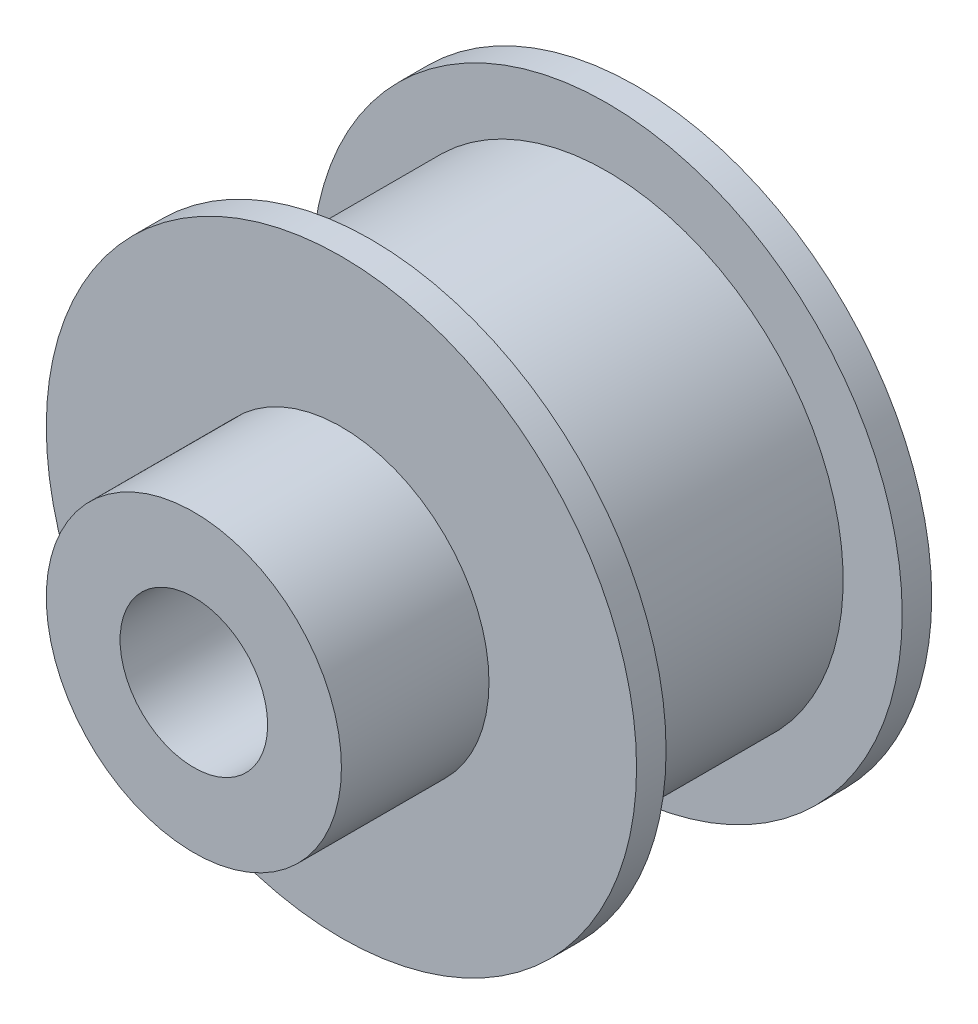
from build123d import *

# Parameters (mm, degrees)
ESQUISSE1_R             = 10
BOSS_EXTRU_1_DEPTH      = 10
ESQUISSE2_R             = 5
BOSS_EXTRU_2_DEPTH      = 5
ESQUISSE3_R             = 2.5
ENL_V_MAT_EXTRU_1_DEPTH = 16
ESQUISSE4_W             = 8
ESQUISSE4_H             = 2


with BuildPart() as part:
    # Esquisse1 → Boss.-Extru.1 (new body)
    with BuildSketch(Plane.XY):
        Circle(ESQUISSE1_R)
    extrude(amount=BOSS_EXTRU_1_DEPTH)

    # Esquisse2 → Boss.-Extru.2 (add)
    with BuildSketch(Plane.XY.offset(10)):
        Circle(ESQUISSE2_R)
    extrude(amount=BOSS_EXTRU_2_DEPTH)

    # Esquisse3 → Enlèv. mat.-Extru.1 (cut, through all)
    with BuildSketch(Plane.XY.offset(15)):
        Circle(ESQUISSE3_R)
    extrude(amount=-ENL_V_MAT_EXTRU_1_DEPTH, mode=Mode.SUBTRACT)

    # Esquisse4 → Enlèvement de matière-Révolution1 (revolve, cut)
    with BuildSketch(Plane(origin=(0, 0, 0), x_dir=(0, 0, -1), z_dir=(1, 0, 0))):
        with Locations((-5, 9)):
            Rectangle(ESQUISSE4_W, ESQUISSE4_H)
    revolve(axis=Axis((0, 0, 0), (0, 0, 1)), mode=Mode.SUBTRACT)


solid = part.part
